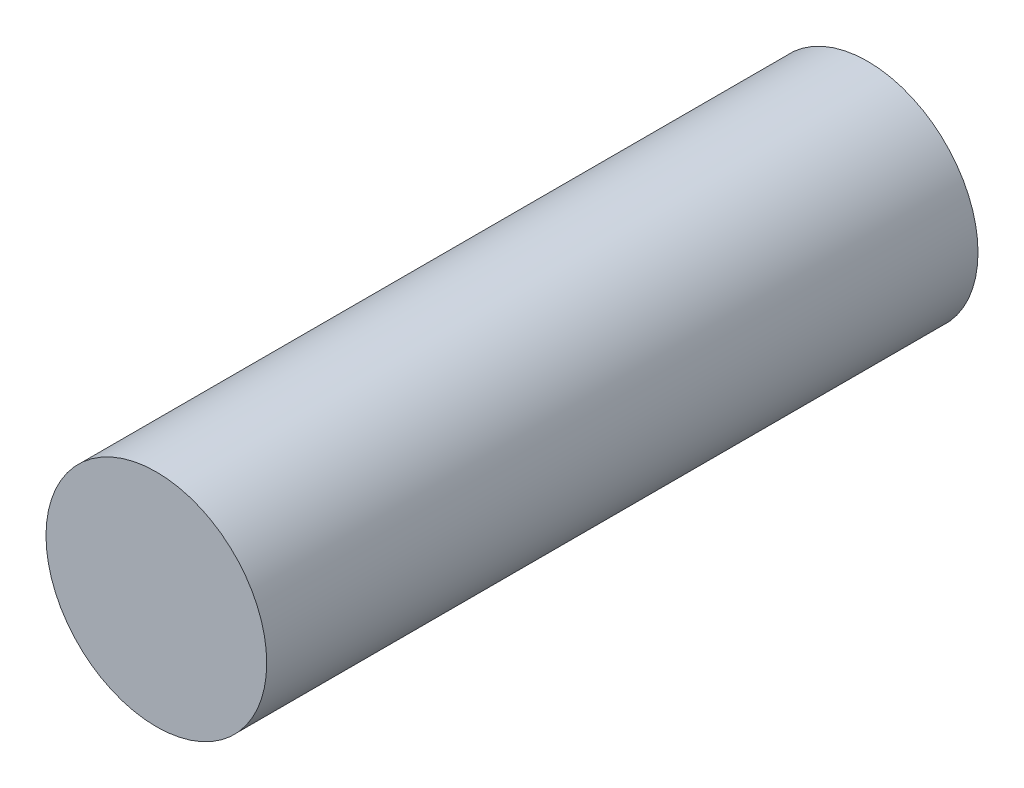
from build123d import *

# Parameters (mm, degrees)
SKETCH_1_R      = 2.5
EXTRUDE_1_DEPTH = 16.112671561


with BuildPart() as part:
    # 草图1 → 凸台-拉伸1 (new body)
    with BuildSketch(Plane.XY):
        with Locations((-0.022660126, -0.006354327)):
            Circle(SKETCH_1_R)
    extrude(amount=EXTRUDE_1_DEPTH)


solid = part.part
